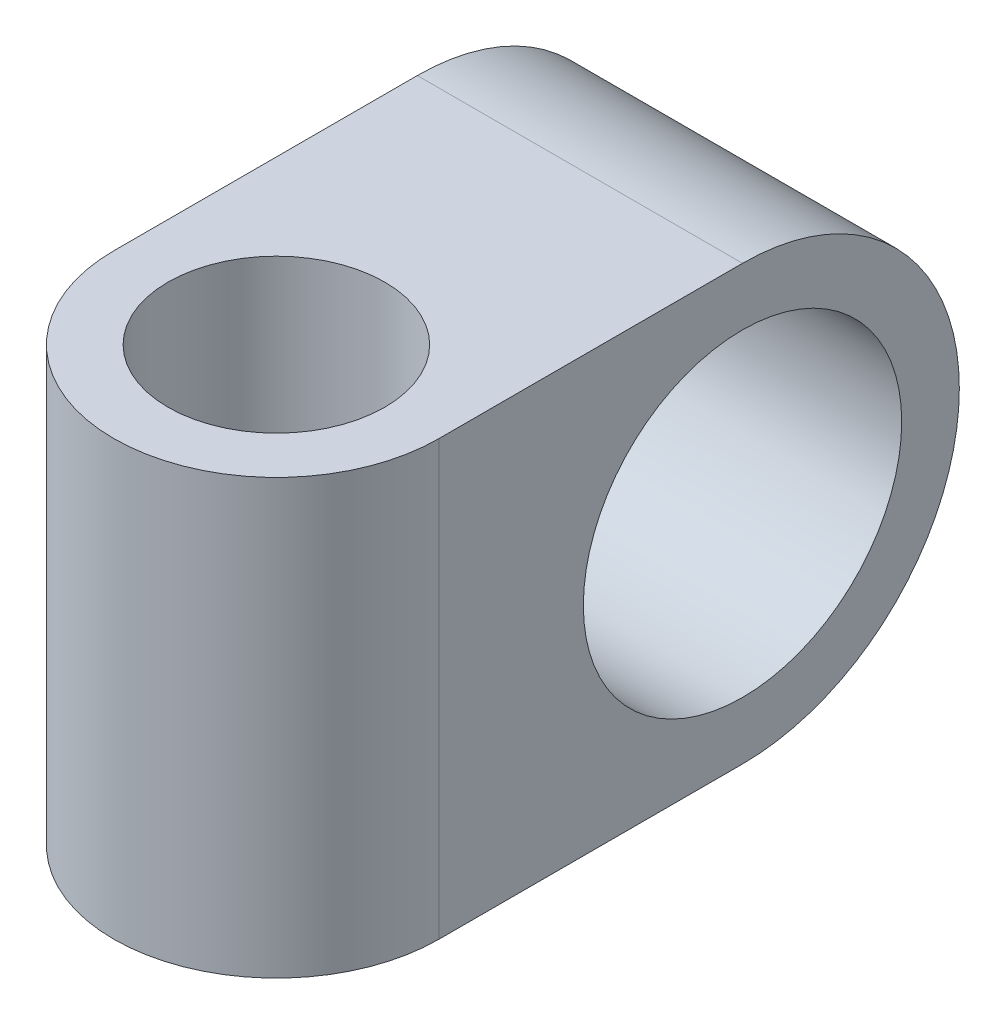
from build123d import *

# Parameters (mm, degrees)
SKETCH1_W               = 22
SKETCH1_H               = 22
EXTRUDE1_DEPTH          = 40
EXTRUDE2_DEPTH          = 43.918527468
EXTRUDE2_DEPTH_BACK     = 43.918527468
EXTRUDE3_DEPTH          = 43.673176587
EXTRUDE3_DEPTH_BACK     = 43.673176587
SKETCH3_R               = 5
F_5_8_18_TAPPED_HOLE1_D = 14.68374


with BuildPart() as part:
    # Sketch1 → Extrude1 (new body)
    with BuildSketch(Plane.XY):
        Rectangle(SKETCH1_W, SKETCH1_H)
    extrude(amount=EXTRUDE1_DEPTH)

    # Sketch2 → Extrude2 (cut, two sides: drawn at the far end of the back side and taken through both)
    with BuildSketch(Plane(origin=(0, 0, 0), x_dir=(0, 0, -1), z_dir=(1, 0, 0)).offset(-EXTRUDE2_DEPTH_BACK)):
        with BuildLine():
            Line((-11, -10), (-49.420419849, -10))
            Line((-49.420419849, -10), (-49.420419849, -16.887372299))
            Line((-49.420419849, -16.887372299), (-11, -16.887372299))
            Line((-11, -16.887372299), (8.616222101, -16.887372299))
            Line((8.616222101, -16.887372299), (8.616222101, 23.046405641))
            Line((8.616222101, 23.046405641), (-11, 23.046405641))
            Line((-11, 23.046405641), (-49.420419849, 23.046405641))
            Line((-49.420419849, 23.046405641), (-49.420419849, 10))
            Line((-49.420419849, 10), (-11, 10))
            ThreePointArc((-11, 10), (-1, 0), (-11, -10))
        make_face()
    extrude(amount=EXTRUDE2_DEPTH + EXTRUDE2_DEPTH_BACK, mode=Mode.SUBTRACT)

    # Sketch3 → Extrude3 (cut, two sides: drawn at the far end of the back side and taken through both)
    with BuildSketch(Plane(origin=(0, 0, 0), x_dir=(1, 0, 0), z_dir=(0, 1, 0)).offset(-EXTRUDE3_DEPTH_BACK)):
        with Locations((0, -25)):
            Circle(SKETCH3_R)
        with BuildLine():
            Line((-18.844545226, 6.847618329), (-7.5, 6.847618329))
            Line((-7.5, 6.847618329), (-7.5, -25))
            ThreePointArc((-7.5, -25), (0, -32.5), (7.5, -25))
            Line((7.5, -25), (7.5, 6.847618329))
            Line((7.5, 6.847618329), (23.30888992, 6.847618329))
            Line((23.30888992, 6.847618329), (23.30888992, -44.330247861))
            Line((23.30888992, -44.330247861), (-18.844545226, -44.330247861))
            Line((-18.844545226, -44.330247861), (-18.844545226, 6.847618329))
        make_face()
    extrude(amount=EXTRUDE3_DEPTH + EXTRUDE3_DEPTH_BACK, mode=Mode.SUBTRACT)

    # 5_8-18 Tapped Hole1 (through all)
    with Locations(Plane(origin=(7.5, 0, 0), x_dir=(0, 0, -1), z_dir=(1, 0, 0))):
        with Locations((-11, 0)):
            Hole(F_5_8_18_TAPPED_HOLE1_D / 2)


solid = part.part
